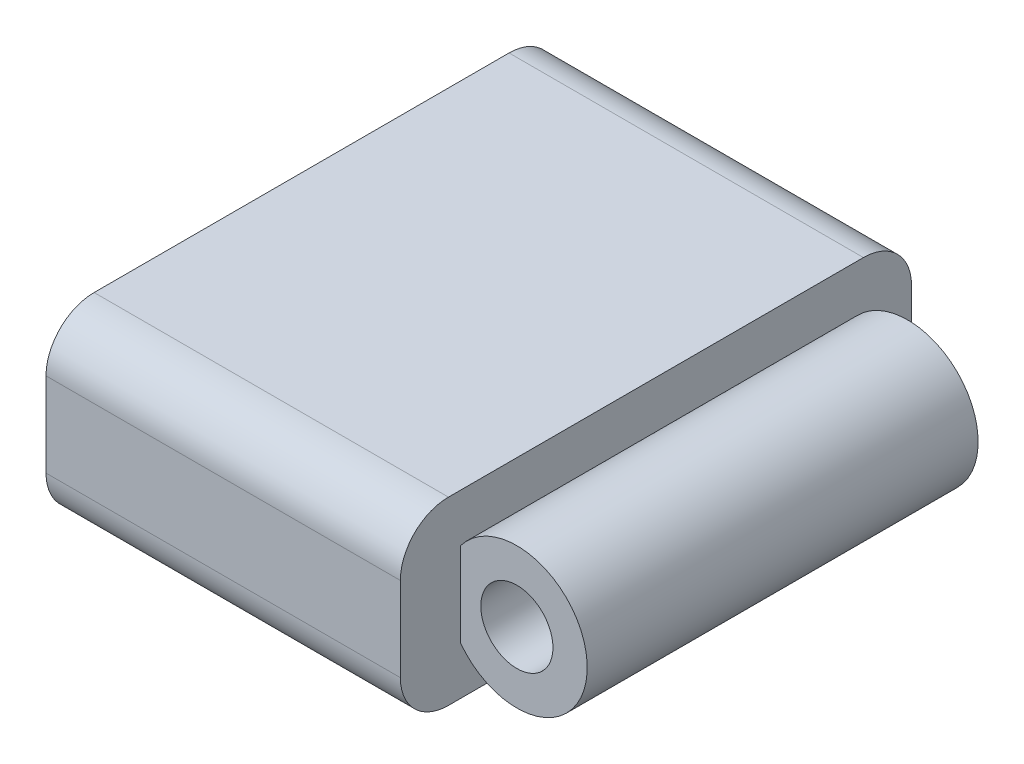
from build123d import *

# Parameters (mm, degrees)
SKETCH1_W           = 50.8
SKETCH1_H           = 53.975
BOSS_EXTRUDE1_DEPTH = 19.05
FILLET1_R           = 5.08
CUT_EXTRUDE1_DEPTH  = 54.975
SKETCH3_W           = 14.750075479
SKETCH3_H           = 6.35
SKETCH3_W_2         = 17.214026843
CUT_EXTRUDE2_DEPTH  = 19.05
SKETCH4_R           = 3.81
CUT_EXTRUDE3_DEPTH  = 48.625
SKETCH5_W           = 40.64
SKETCH5_H           = 15.24
CUT_EXTRUDE4_DEPTH  = 17.78
FILLET2_R           = 2.54


with BuildPart() as part:
    # Sketch1 → Boss-Extrude1 (new body)
    with BuildSketch(Plane(origin=(0, 0, 0), x_dir=(1, 0, 0), z_dir=(0, 1, 0))):
        with Locations((25.4, 26.9875)):
            Rectangle(SKETCH1_W, SKETCH1_H)
    extrude(amount=BOSS_EXTRUDE1_DEPTH)

    # Fillet1
    fillet1_edges = [part.edges().sort_by_distance(p)[0] for p in [
        (25.4, 19.05, -53.975),
        (25.4, 0, -53.975),
        (25.4, 0, 0),
        (25.4, 19.05, 0),
    ]]
    fillet(fillet1_edges, radius=FILLET1_R)

    # Sketch2 → Cut-Extrude1 (cut, through all)
    with BuildSketch(Plane.XY):
        with BuildLine():
            Line((50.8, 19.05), (37.417396167, 19.05))
            Line((37.417396167, 19.05), (37.417396167, 13.97))
            ThreePointArc((37.417396167, 13.97), (43.3705, 16.9545), (49.323603833, 13.97))
            Line((49.323603833, 13.97), (50.8, 13.97))
            Line((50.8, 13.97), (50.8, 19.05))
        make_face()
        with BuildLine():
            Line((50.8, 13.97), (49.323603833, 13.97))
            ThreePointArc((49.323603833, 13.97), (50.421246598, 11.866888695), (50.8, 9.525))
            Line((50.8, 9.525), (50.8, 13.97))
        make_face()
        with BuildLine():
            ThreePointArc((50.8, 9.525), (50.421246598, 7.183111305), (49.323603833, 5.08))
            Line((49.323603833, 5.08), (50.8, 5.08))
            Line((50.8, 5.08), (50.8, 9.525))
        make_face()
        with BuildLine():
            ThreePointArc((49.323603833, 5.08), (43.3705, 2.0955), (37.417396167, 5.08))
            Line((37.417396167, 5.08), (37.417396167, 0))
            Line((37.417396167, 0), (50.8, 0))
            Line((50.8, 0), (50.8, 5.08))
            Line((50.8, 5.08), (49.323603833, 5.08))
        make_face()
    extrude(amount=-CUT_EXTRUDE1_DEPTH, mode=Mode.SUBTRACT)

    # Sketch3 → Cut-Extrude2 (cut)
    with BuildSketch(Plane(origin=(0, 19.05, 0), x_dir=(1, 0, 0), z_dir=(0, 1, 0))):
        with Locations((44.792433907, 3.175)):
            Rectangle(SKETCH3_W, SKETCH3_H)
        with Locations((46.024409589, 50.8)):
            Rectangle(SKETCH3_W_2, SKETCH3_H)
    extrude(amount=-CUT_EXTRUDE2_DEPTH, mode=Mode.SUBTRACT)

    # Sketch4 → Cut-Extrude3 (cut, through all)
    with BuildSketch(Plane.XY.offset(-6.35)):
        with Locations((43.3705, 9.525)):
            Circle(SKETCH4_R)
    extrude(amount=-CUT_EXTRUDE3_DEPTH, mode=Mode.SUBTRACT)

    # Sketch5 → Cut-Extrude4 (cut)
    with BuildSketch(Plane.ZY):
        with Locations((-26.9875, 9.525)):
            Rectangle(SKETCH5_W, SKETCH5_H)
    extrude(amount=-CUT_EXTRUDE4_DEPTH, mode=Mode.SUBTRACT)

    # Fillet2
    fillet2_edges = [part.edges().sort_by_distance(p)[0] for p in [
        (8.89, 1.905, -47.3075),
        (8.89, 17.145, -47.3075),
        (8.89, 17.145, -6.6675),
        (8.89, 1.905, -6.6675),
    ]]
    fillet(fillet2_edges, radius=FILLET2_R)


solid = part.part
